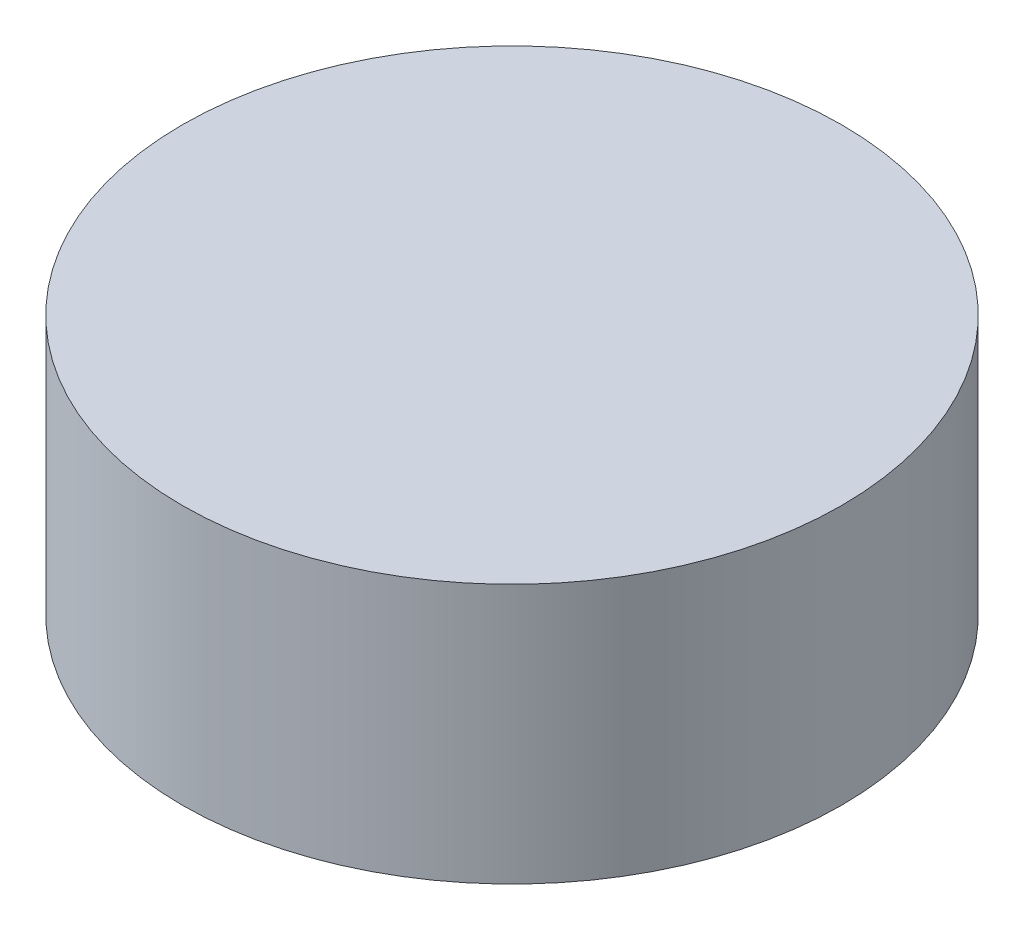
from build123d import *

# Parameters (mm, degrees)
SKETCH1_R           = 12.7
BOSS_EXTRUDE1_DEPTH = 10


with BuildPart() as part:
    # Sketch1 → Boss-Extrude1 (new body)
    with BuildSketch(Plane(origin=(0, 0, 0), x_dir=(1, 0, 0), z_dir=(0, 1, 0))):
        Circle(SKETCH1_R)
    extrude(amount=BOSS_EXTRUDE1_DEPTH)


solid = part.part
